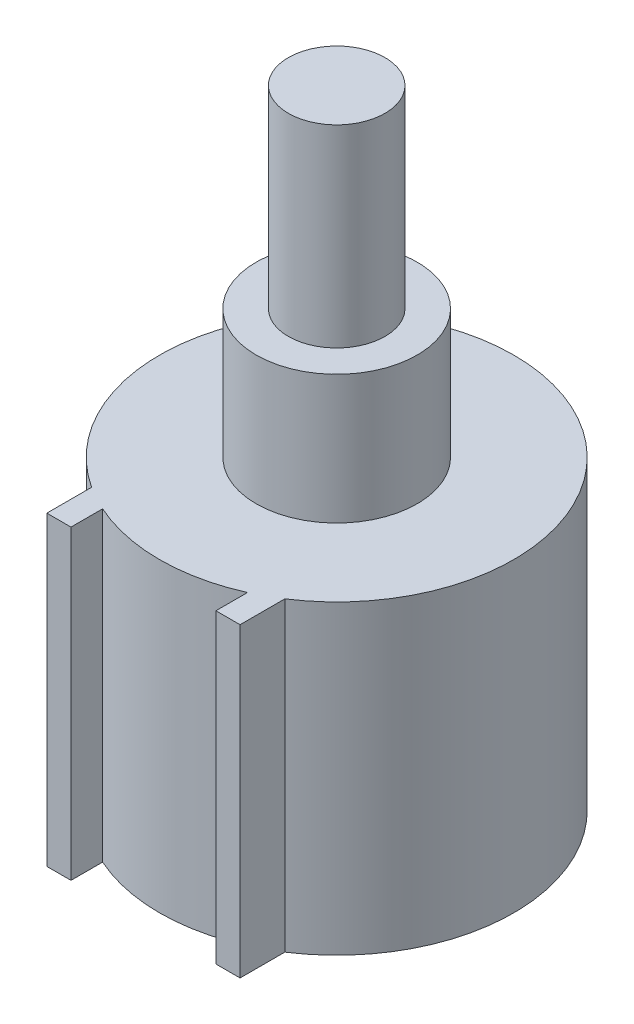
from build123d import *

# Parameters (mm, degrees)
BOSS_EXTRUDE1_DEPTH = 19
SKETCH2_R           = 5
BOSS_EXTRUDE2_DEPTH = 8
SKETCH3_R           = 3
BOSS_EXTRUDE3_DEPTH = 12


with BuildPart() as part:
    # Sketch1 → Boss-Extrude1 (new body)
    with BuildSketch(Plane(origin=(0, 0, 0), x_dir=(1, 0, 0), z_dir=(0, 1, 0))):
        with BuildLine():
            Line((-6, -12), (-4.5, -12))
            Line((-4.5, -12), (-4.5, -10.03742995))
            ThreePointArc((-4.5, -10.03742995), (0, -11), (4.5, -10.03742995))
            Line((4.5, -10.03742995), (4.5, -12))
            Line((4.5, -12), (6, -12))
            Line((6, -12), (6, -9.219544457))
            ThreePointArc((6, -9.219544457), (0, 11), (-6, -9.219544457))
            Line((-6, -9.219544457), (-6, -12))
        make_face()
    extrude(amount=BOSS_EXTRUDE1_DEPTH)

    # Sketch2 → Boss-Extrude2 (add)
    with BuildSketch(Plane(origin=(0, 19, 0), x_dir=(1, 0, 0), z_dir=(0, 1, 0))):
        Circle(SKETCH2_R)
    extrude(amount=BOSS_EXTRUDE2_DEPTH)

    # Sketch3 → Boss-Extrude3 (add)
    with BuildSketch(Plane(origin=(0, 27, 0), x_dir=(1, 0, 0), z_dir=(0, 1, 0))):
        Circle(SKETCH3_R)
    extrude(amount=BOSS_EXTRUDE3_DEPTH)


solid = part.part
